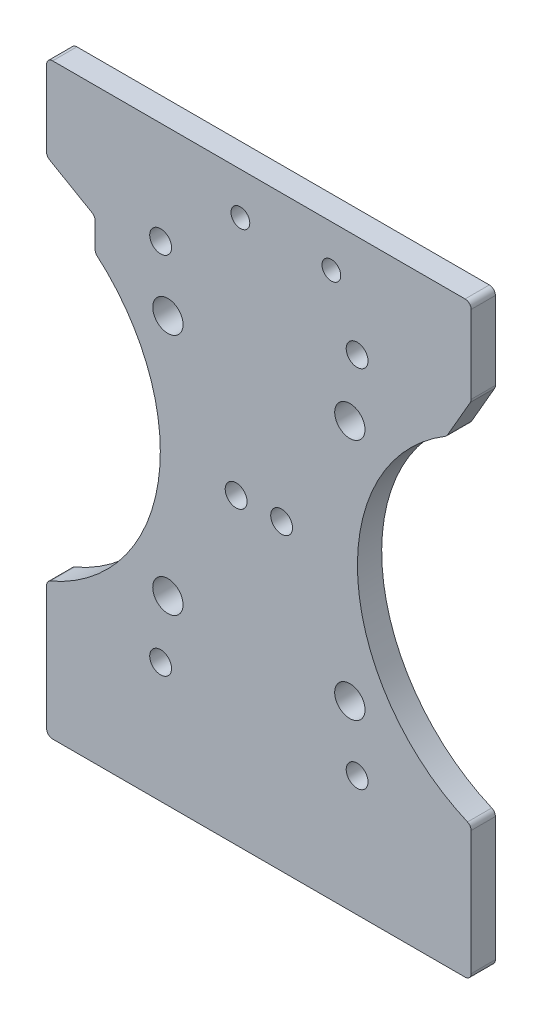
from build123d import *

# Parameters (mm, degrees)
SKETCH_1_R          = 1.8
SKETCH_1_R_2        = 1.55
EXTRUDE_1_DEPTH     = 4
SKETCH_3_R          = 2.5
CUT_EXTRUDE_2_DEPTH = 10
FILLET_1_R          = 1


with BuildPart() as part:
    # 草图1 → 凸台-拉伸1 (new body)
    with BuildSketch(Plane.XY):
        with BuildLine():
            Line((35, 46.920144927), (-35, 46.920144927))
            Line((-35, 46.920144927), (-35, 32.810744327))
            Line((-35, 32.810744327), (-27, 28.191942173))
            Line((-27, 28.191942173), (-27, 23.009508904))
            ThreePointArc((-27, 23.009508904), (-16.614935725, -4.665079356), (-35, -27.810744327))
            Line((-35, -27.810744327), (-35, -46.920144927))
            Line((-35, -46.920144927), (-35, -49.920144927))
            Line((-35, -49.920144927), (35, -49.920144927))
            Line((35, -49.920144927), (35, -46.920144927))
            Line((35, -46.920144927), (35, -27.810744327))
            ThreePointArc((35, -27.810744327), (16.334866743, -2.254950607), (30.958156738, 25.81006644))
            Line((30.958156738, 25.81006644), (35, 32.810744327))
            Line((35, 32.810744327), (35, 46.920144927))
        make_face()
        with Locations((-16.1979618, -30.0520382)):
            Circle(SKETCH_1_R, mode=Mode.SUBTRACT)
        with Locations((16.1979618, -30.0520382)):
            Circle(SKETCH_1_R, mode=Mode.SUBTRACT)
        with Locations((-3.75, 0)):
            Circle(SKETCH_1_R, mode=Mode.SUBTRACT)
        with Locations((-16.1979618, 30.0520382)):
            Circle(SKETCH_1_R, mode=Mode.SUBTRACT)
        with Locations((-3.05, 40)):
            Circle(SKETCH_1_R_2, mode=Mode.SUBTRACT)
        with Locations((3.75, 0)):
            Circle(SKETCH_1_R, mode=Mode.SUBTRACT)
        with Locations((16.1979618, 30.0520382)):
            Circle(SKETCH_1_R, mode=Mode.SUBTRACT)
        with Locations((11.95, 40)):
            Circle(SKETCH_1_R_2, mode=Mode.SUBTRACT)
    extrude(amount=EXTRUDE_1_DEPTH)

    # 草图3 → 切除-拉伸2 (cut)
    with BuildSketch(Plane(origin=(0, 0, 0), x_dir=(-1, 0, 0), z_dir=(0, 0, -1))):
        with Locations((-15, 20)):
            Circle(SKETCH_3_R)
        with Locations((15, 20)):
            Circle(SKETCH_3_R)
        with Locations((15, -20)):
            Circle(SKETCH_3_R)
        with Locations((-15, -20)):
            Circle(SKETCH_3_R)
    extrude(amount=-CUT_EXTRUDE_2_DEPTH, mode=Mode.SUBTRACT)

    # 圆角1
    fillet_1_edges = [part.edges().sort_by_distance(p)[0] for p in [
        (35, -27.810744327, 2),
        (35, -49.920144927, 2),
        (-35, -49.920144927, 2),
        (-35, -27.810744327, 2),
        (-27, 23.009508904, 2),
        (-27, 28.191942173, 2),
        (-35, 32.810744327, 2),
        (-35, 46.920144927, 2),
        (35, 46.920144927, 2),
        (35, 32.810744327, 2),
        (30.958156738, 25.81006644, 2),
    ]]
    fillet(fillet_1_edges, radius=FILLET_1_R)


solid = part.part
